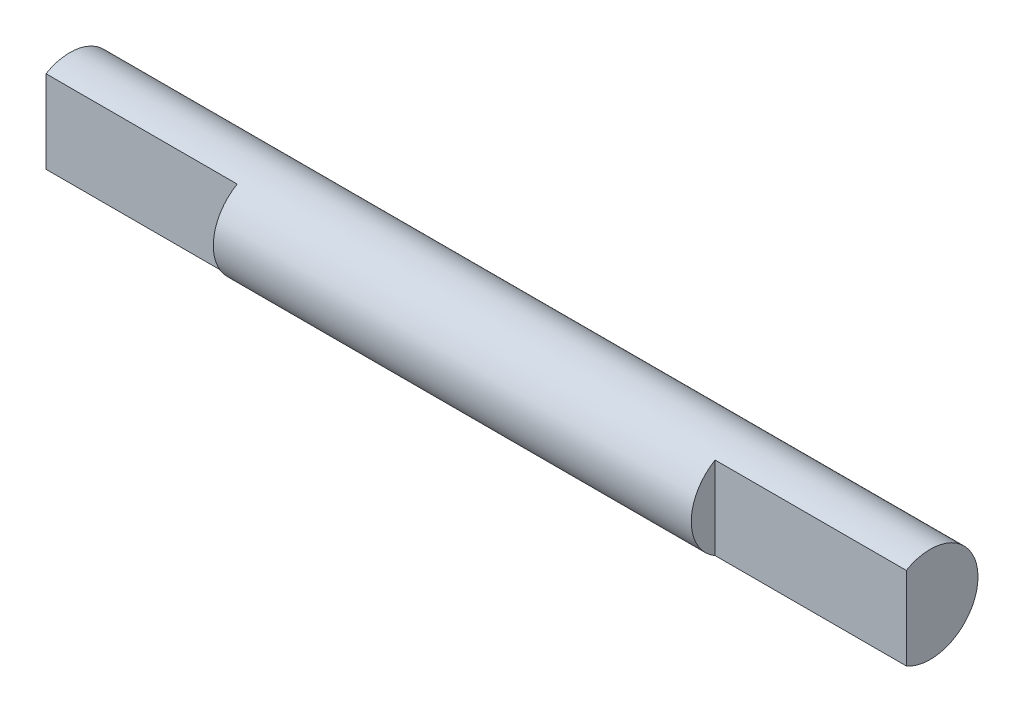
from build123d import *

# Parameters (mm, degrees)
SKETCH1_R           = 12.7
BOSS_EXTRUDE1_DEPTH = 63.5
BOSS_EXTRUDE2_DEPTH = 50.8


with BuildPart() as part:
    # Sketch1 → Boss-Extrude1 (new body, symmetric)
    with BuildSketch(Plane(origin=(0, 0, 0), x_dir=(0, 0, -1), z_dir=(1, 0, 0))):
        Circle(SKETCH1_R)
    extrude(amount=BOSS_EXTRUDE1_DEPTH, both=True)

    # Sketch2 → Boss-Extrude2 (add)
    with BuildSketch(Plane(origin=(63.5, 0, 0), x_dir=(0, 0, -1), z_dir=(1, 0, 0))):
        with BuildLine():
            ThreePointArc((12.7, 0), (6.35, 10.998522628), (-6.35, 10.998522628))
            Line((-6.35, 10.998522628), (-6.35, -10.998522628))
            ThreePointArc((-6.35, -10.998522628), (6.35, -10.998522628), (12.7, 0))
        make_face()
    boss_extrude2 = extrude(amount=BOSS_EXTRUDE2_DEPTH)

    # Mirror1: Boss-Extrude2 across plane
    add(boss_extrude2.mirror(Plane(origin=(0, 0, 0), x_dir=(0, 0, 1), z_dir=(1, 0, 0))))


solid = part.part
